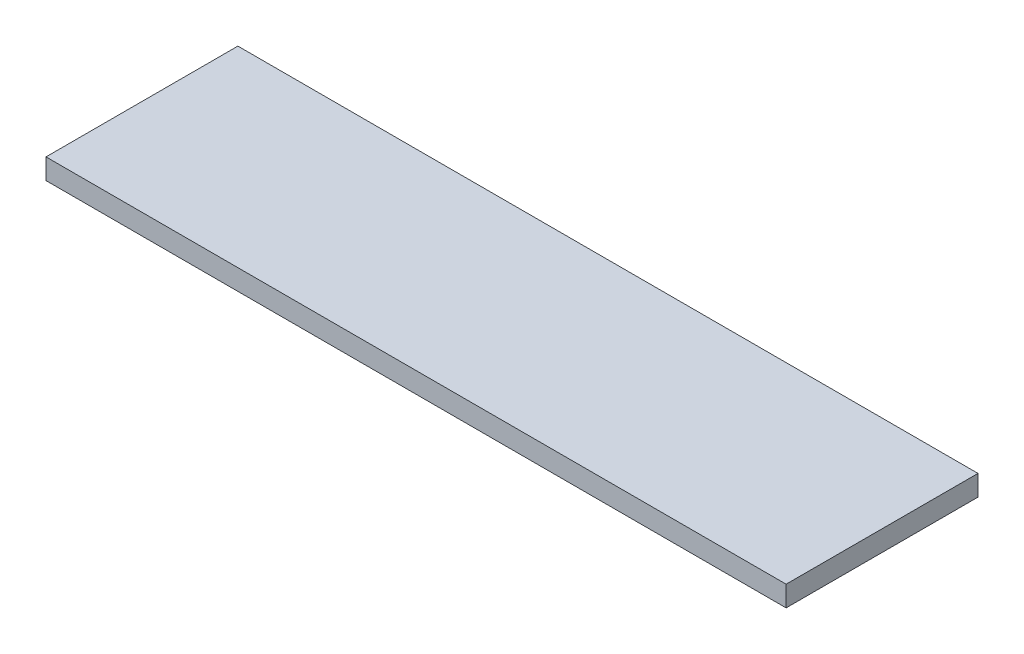
from build123d import *

# Parameters (mm, degrees)
SKETCH1_W           = 685.8
SKETCH1_H           = 177.8
BOSS_EXTRUDE1_DEPTH = 9.525


with BuildPart() as part:
    # Sketch1 → Boss-Extrude1 (new body, symmetric)
    with BuildSketch(Plane(origin=(0, 0, 0), x_dir=(1, 0, 0), z_dir=(0, 1, 0))):
        Rectangle(SKETCH1_W, SKETCH1_H)
    extrude(amount=BOSS_EXTRUDE1_DEPTH, both=True)


solid = part.part
